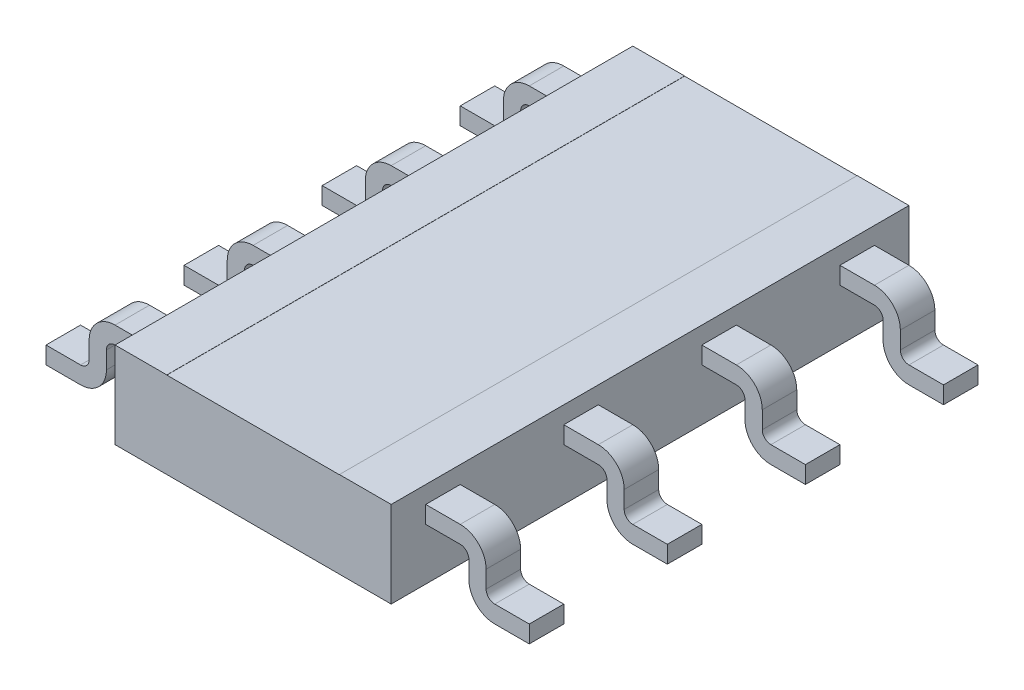
from build123d import *

# Parameters (mm, degrees)
BASES_W              = 1.6
BASES_H              = 3
BASE_DEPTH           = 0.25
MIDDLELEG_DEPTH      = 0.1
LPATTERN1_COUNT      = 4
LPATTERN1_PITCH      = 0.8
MIRROR1_COPY_1_DEPTH = 0.1
MIRROR1_COPY_2_DEPTH = 0.1
MIRROR1_COPY_3_DEPTH = 0.1
TEXTCUTS_W           = 1
TEXTCUTS_H           = 3
TEXTCUT_DEPTH        = 0.001


with BuildPart() as part:
    # BaseS → Base (new body, symmetric)
    with BuildSketch(Plane(origin=(0, 0, 0), x_dir=(1, 0, 0), z_dir=(0, 1, 0))):
        Rectangle(BASES_W, BASES_H)
    extrude(amount=BASE_DEPTH, both=True)

    # MiddleLegS → MiddleLeg (add, symmetric)
    with BuildSketch(Plane.XY.offset(1.2)):
        with BuildLine():
            Line((1.4, -0.15), (1.2, -0.15))
            ThreePointArc((1.2, -0.15), (1.164644661, -0.135355339), (1.15, -0.1))
            Line((1.15, -0.1), (1.15, 0))
            ThreePointArc((1.15, 0), (1.106066017, 0.106066017), (1, 0.15))
            Line((1, 0.15), (0.8, 0.15))
            Line((0.8, 0.15), (0.8, 0.05))
            Line((0.8, 0.05), (1, 0.05))
            ThreePointArc((1, 0.05), (1.035355339, 0.035355339), (1.05, 0))
            Line((1.05, 0), (1.05, -0.1))
            ThreePointArc((1.05, -0.1), (1.093933983, -0.206066017), (1.2, -0.25))
            Line((1.2, -0.25), (1.4, -0.25))
            Line((1.4, -0.25), (1.4, -0.15))
        make_face()
    middleleg = extrude(amount=MIDDLELEG_DEPTH, both=True)

    # LPattern1: MiddleLeg ×4
    with Locations(*[(0, 0, -i * LPATTERN1_PITCH) for i in range(1, LPATTERN1_COUNT)]):
        add(middleleg)

    # Mirror1: MiddleLeg across plane
    add(middleleg.mirror(Plane(origin=(0, 0, 0), x_dir=(0, 0, 1), z_dir=(1, 0, 0))))

    # Mirror1 copy 1 sketch → Mirror1 copy 1 (add, symmetric)
    with BuildSketch(Plane(origin=(0, 0, 0.4), x_dir=(-1, 0, 0), z_dir=(0, 0, 1))):
        with BuildLine():
            Line((1.4, 0.15), (1.2, 0.15))
            ThreePointArc((1.2, 0.15), (1.164644661, 0.135355339), (1.15, 0.1))
            Line((1.15, 0.1), (1.15, 0))
            ThreePointArc((1.15, 0), (1.106066017, -0.106066017), (1, -0.15))
            Line((1, -0.15), (0.8, -0.15))
            Line((0.8, -0.15), (0.8, -0.05))
            Line((0.8, -0.05), (1, -0.05))
            ThreePointArc((1, -0.05), (1.035355339, -0.035355339), (1.05, 0))
            Line((1.05, 0), (1.05, 0.1))
            ThreePointArc((1.05, 0.1), (1.093933983, 0.206066017), (1.2, 0.25))
            Line((1.2, 0.25), (1.4, 0.25))
            Line((1.4, 0.25), (1.4, 0.15))
        make_face()
    extrude(amount=MIRROR1_COPY_1_DEPTH, both=True)

    # Mirror1 copy 2 sketch → Mirror1 copy 2 (add, symmetric)
    with BuildSketch(Plane(origin=(0, 0, -0.4), x_dir=(-1, 0, 0), z_dir=(0, 0, 1))):
        with BuildLine():
            Line((1.4, 0.15), (1.2, 0.15))
            ThreePointArc((1.2, 0.15), (1.164644661, 0.135355339), (1.15, 0.1))
            Line((1.15, 0.1), (1.15, 0))
            ThreePointArc((1.15, 0), (1.106066017, -0.106066017), (1, -0.15))
            Line((1, -0.15), (0.8, -0.15))
            Line((0.8, -0.15), (0.8, -0.05))
            Line((0.8, -0.05), (1, -0.05))
            ThreePointArc((1, -0.05), (1.035355339, -0.035355339), (1.05, 0))
            Line((1.05, 0), (1.05, 0.1))
            ThreePointArc((1.05, 0.1), (1.093933983, 0.206066017), (1.2, 0.25))
            Line((1.2, 0.25), (1.4, 0.25))
            Line((1.4, 0.25), (1.4, 0.15))
        make_face()
    extrude(amount=MIRROR1_COPY_2_DEPTH, both=True)

    # Mirror1 copy 3 sketch → Mirror1 copy 3 (add, symmetric)
    with BuildSketch(Plane(origin=(0, 0, -1.2), x_dir=(-1, 0, 0), z_dir=(0, 0, 1))):
        with BuildLine():
            Line((1.4, 0.15), (1.2, 0.15))
            ThreePointArc((1.2, 0.15), (1.164644661, 0.135355339), (1.15, 0.1))
            Line((1.15, 0.1), (1.15, 0))
            ThreePointArc((1.15, 0), (1.106066017, -0.106066017), (1, -0.15))
            Line((1, -0.15), (0.8, -0.15))
            Line((0.8, -0.15), (0.8, -0.05))
            Line((0.8, -0.05), (1, -0.05))
            ThreePointArc((1, -0.05), (1.035355339, -0.035355339), (1.05, 0))
            Line((1.05, 0), (1.05, 0.1))
            ThreePointArc((1.05, 0.1), (1.093933983, 0.206066017), (1.2, 0.25))
            Line((1.2, 0.25), (1.4, 0.25))
            Line((1.4, 0.25), (1.4, 0.15))
        make_face()
    extrude(amount=MIRROR1_COPY_3_DEPTH, both=True)

    # TextCutS → TextCut (cut)
    with BuildSketch(Plane(origin=(0, 0.25, 0), x_dir=(1, 0, 0), z_dir=(0, 1, 0))):
        Rectangle(TEXTCUTS_W, TEXTCUTS_H)
    extrude(amount=-TEXTCUT_DEPTH, mode=Mode.SUBTRACT)


solid = part.part
